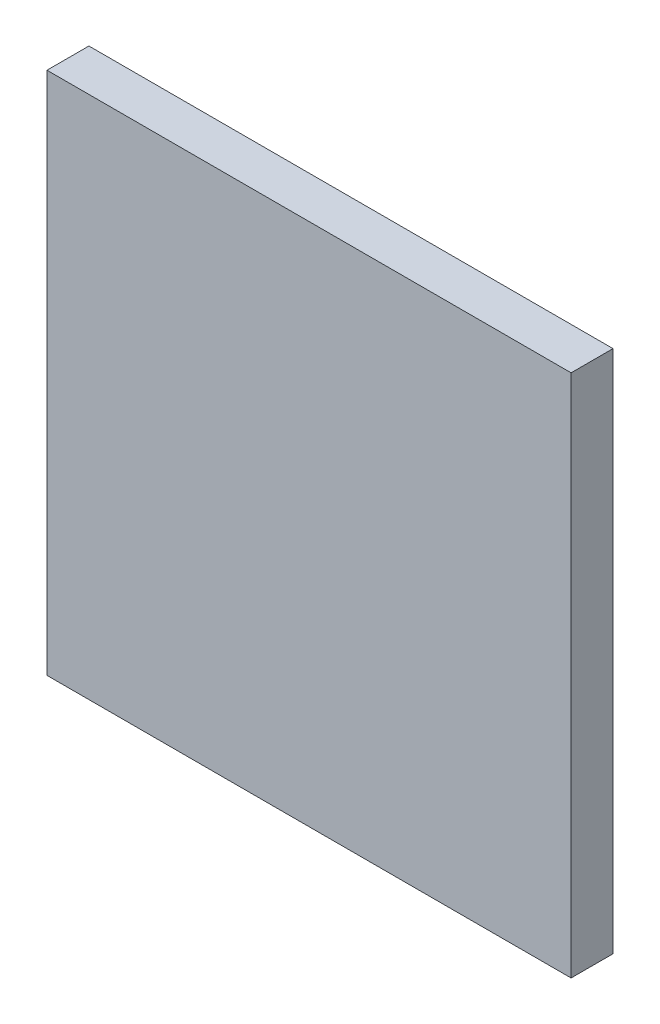
from build123d import *

# Parameters (mm, degrees)
SKETCH1_W           = 50
SKETCH1_H           = 50
BOSS_EXTRUDE1_DEPTH = 4


with BuildPart() as part:
    # Sketch1 → Boss-Extrude1 (new body)
    with BuildSketch(Plane.XY):
        with Locations((25, 25)):
            Rectangle(SKETCH1_W, SKETCH1_H)
    extrude(amount=BOSS_EXTRUDE1_DEPTH)


solid = part.part
